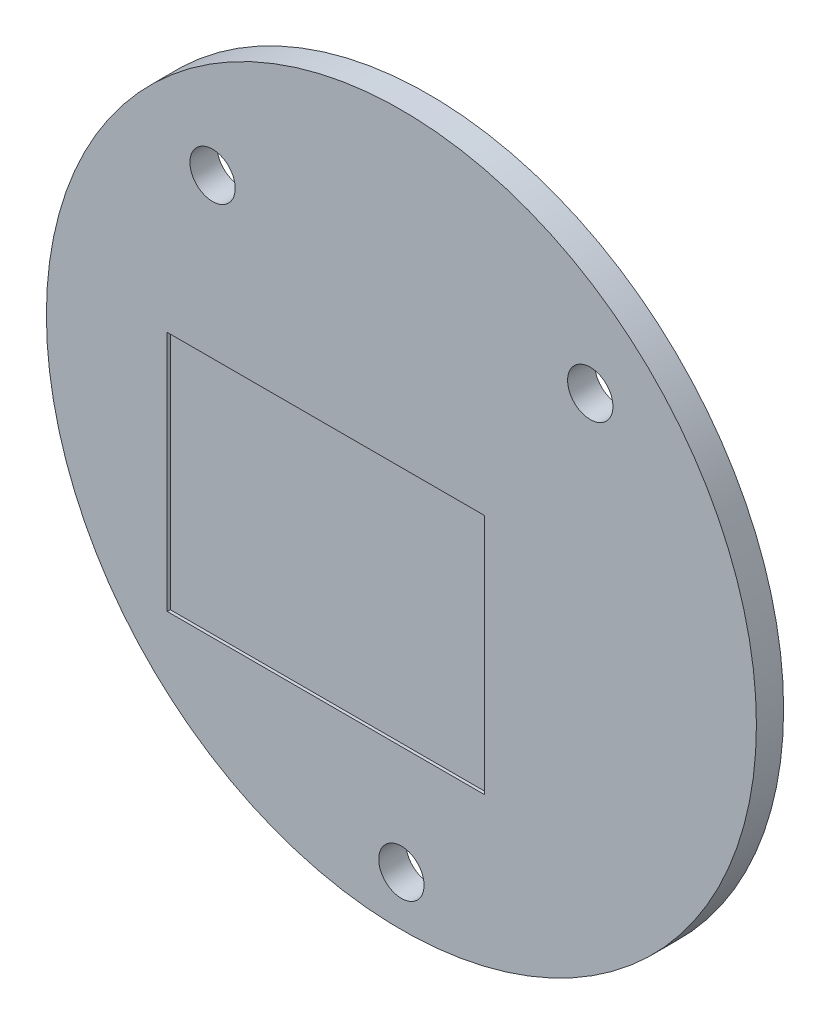
from build123d import *

# Parameters (mm, degrees)
CROQUIS1_R              = 23.5
CROQUIS1_R_2            = 1.5
SALIENTE_EXTRUIR1_DEPTH = 1.8
CROQUIS2_W              = 21
CROQUIS2_H              = 16
CORTAR_EXTRUIR1_DEPTH   = 0.2


with BuildPart() as part:
    # Croquis1 → Saliente-Extruir1 (new body)
    with BuildSketch(Plane.XY):
        Circle(CROQUIS1_R)
        with Locations((0, -20.2)):
            Circle(CROQUIS1_R_2, mode=Mode.SUBTRACT)
        with Locations((-12.5, 13.5)):
            Circle(CROQUIS1_R_2, mode=Mode.SUBTRACT)
        with Locations((12.5, 13.5)):
            Circle(CROQUIS1_R_2, mode=Mode.SUBTRACT)
    extrude(amount=SALIENTE_EXTRUIR1_DEPTH)

    # Croquis2 → Cortar-Extruir1 (cut)
    with BuildSketch(Plane.XY.offset(1.8)):
        with Locations((-5, -5)):
            Rectangle(CROQUIS2_W, CROQUIS2_H)
    extrude(amount=-CORTAR_EXTRUIR1_DEPTH, mode=Mode.SUBTRACT)


solid = part.part
